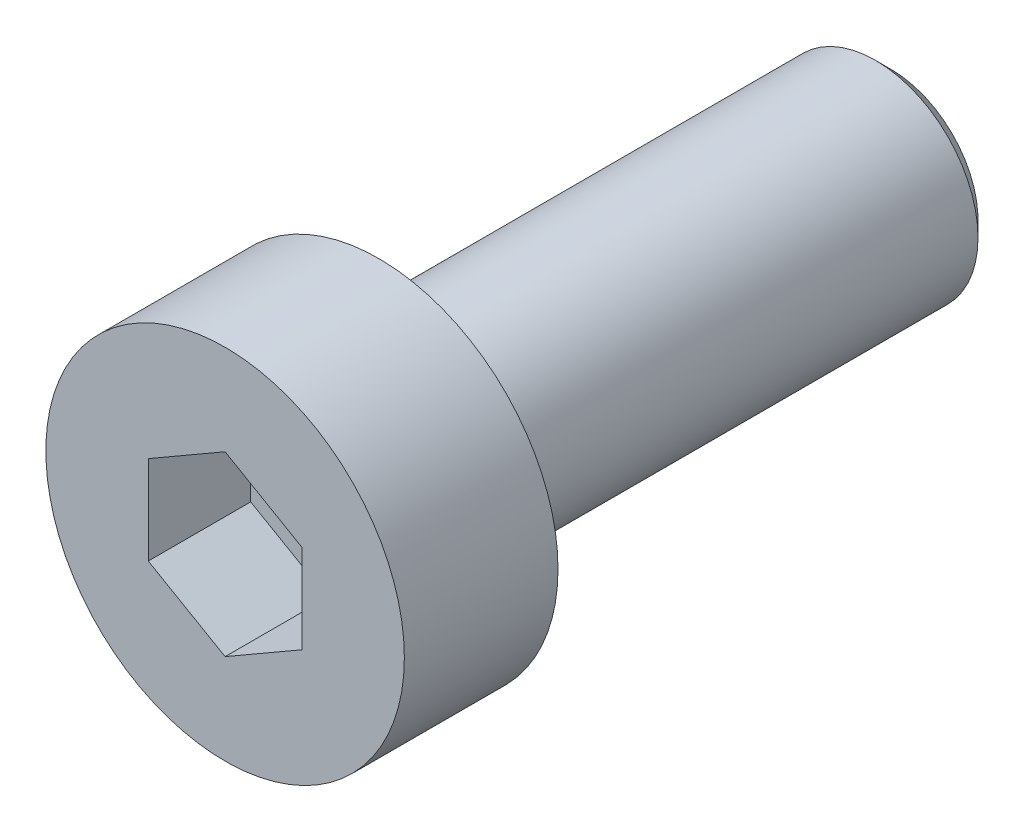
from build123d import *

# Parameters (mm, degrees)
SKETCH1_R           = 3.5
BOSS_EXTRUDE1_DEPTH = 3
SKETCH2_R           = 2
BOSS_EXTRUDE2_DEPTH = 10
CHAMFER1_SIZE       = 0.3
CUT_EXTRUDE1_DEPTH  = 2


with BuildPart() as part:
    # Sketch1 → Boss-Extrude1 (new body)
    with BuildSketch(Plane.XY):
        Circle(SKETCH1_R)
    extrude(amount=BOSS_EXTRUDE1_DEPTH)

    # Sketch2 → Boss-Extrude2 (add)
    with BuildSketch(Plane(origin=(0, 0, 0), x_dir=(-1, 0, 0), z_dir=(0, 0, -1))):
        Circle(SKETCH2_R)
    extrude(amount=BOSS_EXTRUDE2_DEPTH)

    # Chamfer1
    chamfer1_edges = [part.edges().sort_by_distance(p)[0] for p in [
        (2, 0, -10),
    ]]
    chamfer(chamfer1_edges, length=CHAMFER1_SIZE)

    # Sketch3 → Cut-Extrude1 (cut)
    with BuildSketch(Plane.XY.offset(3)):
        Polygon((0, 1.732050808), (-1.5, 0.866025404), (-1.5, -0.866025404), (0, -1.732050808), (1.5, -0.866025404), (1.5, 0.866025404), align=None)
    extrude(amount=-CUT_EXTRUDE1_DEPTH, mode=Mode.SUBTRACT)


solid = part.part
